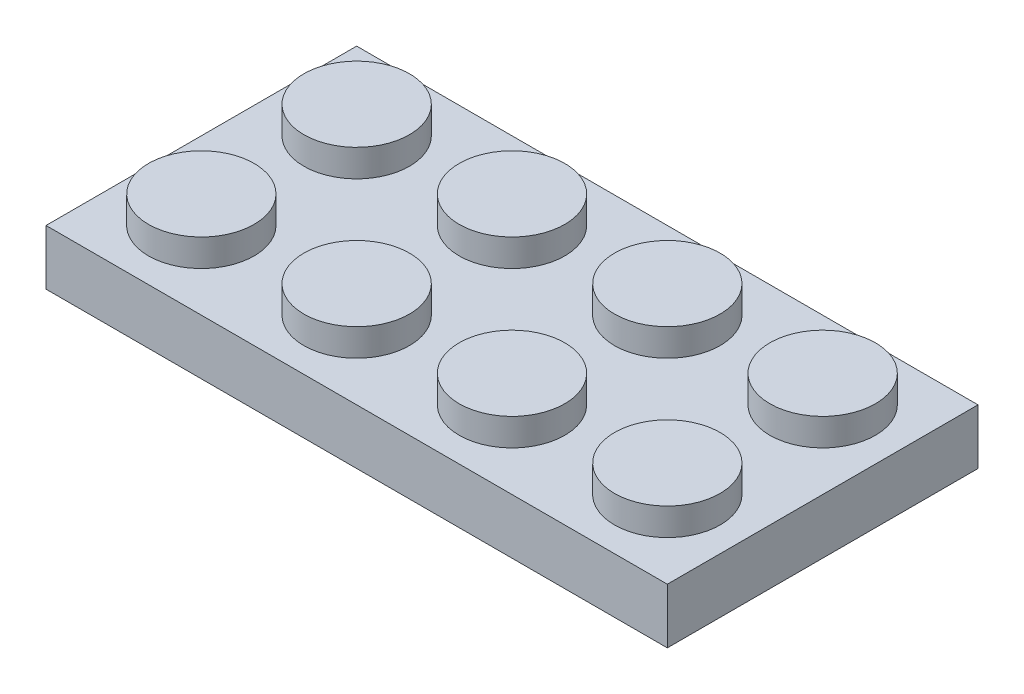
from build123d import *

# Parameters (mm, degrees)
SKETCH1_W            = 31.75
SKETCH1_H            = 15.875
BOSS_EXTRUDE1_DEPTH  = 1.4097
SKETCH2_W            = 29.21
SKETCH2_H            = 13.335
SKETCH2_R            = 3.175
SKETCH2_R_2          = 2.413
CUT_EXTRUDE1_DEPTH   = 1.5494
SKETCH3_R            = 2.69875
BOSS_EXTRUDE2_DEPTH  = 1.397
LPATTERN1_COUNT      = 4
LPATTERN1_PITCH      = 7.9375
LPATTERN1_COUNT_DIR2 = 2
LPATTERN1_PITCH_DIR2 = 7.9375
SKETCH2_3_R          = 3.175
SKETCH2_3_R_2        = 2.413
BOSS_EXTRUDE3_DEPTH  = 1.5494
LPATTERN2_COUNT      = 2
LPATTERN2_PITCH      = 7.9375
LPATTERN2_COL_COUNT  = 2
LPATTERN2_COL_PITCH  = 7.9375


with BuildPart() as part:
    # Sketch1 → Boss-Extrude1 (new, symmetric)
    with BuildSketch(Plane(origin=(0, 0, 0), x_dir=(1, 0, 0), z_dir=(0, 1, 0))):
        Rectangle(SKETCH1_W, SKETCH1_H)
    extrude(amount=BOSS_EXTRUDE1_DEPTH, both=True)

    # Sketch2 → Cut-Extrude1 (cut)
    with BuildSketch(Plane.XZ.offset(1.4097)):
        Rectangle(SKETCH2_W, SKETCH2_H)
        Circle(SKETCH2_R, mode=Mode.SUBTRACT)
        Circle(SKETCH2_R)
        Circle(SKETCH2_R_2, mode=Mode.SUBTRACT)
        Circle(SKETCH2_R_2)
    extrude(amount=-CUT_EXTRUDE1_DEPTH, mode=Mode.SUBTRACT)

    # Sketch3 → Boss-Extrude2 (add)
    with BuildSketch(Plane(origin=(0, 1.4097, 0), x_dir=(1, 0, 0), z_dir=(0, 1, 0))):
        with Locations(Location((11.90625, -3.96875, 0), (0, 0, 270))):
            Circle(SKETCH3_R)
    boss_extrude2 = extrude(amount=BOSS_EXTRUDE2_DEPTH)

    # LPattern1: Boss-Extrude2 4 × 2
    with Locations(*[(-i * LPATTERN1_PITCH, 0, -j * LPATTERN1_PITCH_DIR2) for i in range(LPATTERN1_COUNT) for j in range(LPATTERN1_COUNT_DIR2) if (i, j) != (0, 0)]):
        add(boss_extrude2)

    # Sketch2_3 → Boss-Extrude3 (add)
    with BuildSketch(Plane.XZ.offset(1.4097)):
        with Locations(Location((0, 0, 0), (0, 0, 270))):
            Circle(SKETCH2_3_R)
        with Locations(Location((0, 0, 0), (0, 0, 270))):
            Circle(SKETCH2_3_R_2, mode=Mode.SUBTRACT)
    boss_extrude3 = extrude(amount=-BOSS_EXTRUDE3_DEPTH)

    # LPattern2: Boss-Extrude3 ×2
    with Locations(*[(i * LPATTERN2_PITCH, 0, 0) for i in range(1, LPATTERN2_COUNT)]):
        add(boss_extrude3)

    # LPattern2 col: Boss-Extrude3 ×2
    with Locations(*[(-i * LPATTERN2_COL_PITCH, 0, 0) for i in range(1, LPATTERN2_COL_COUNT)]):
        add(boss_extrude3)


solid = part.part
